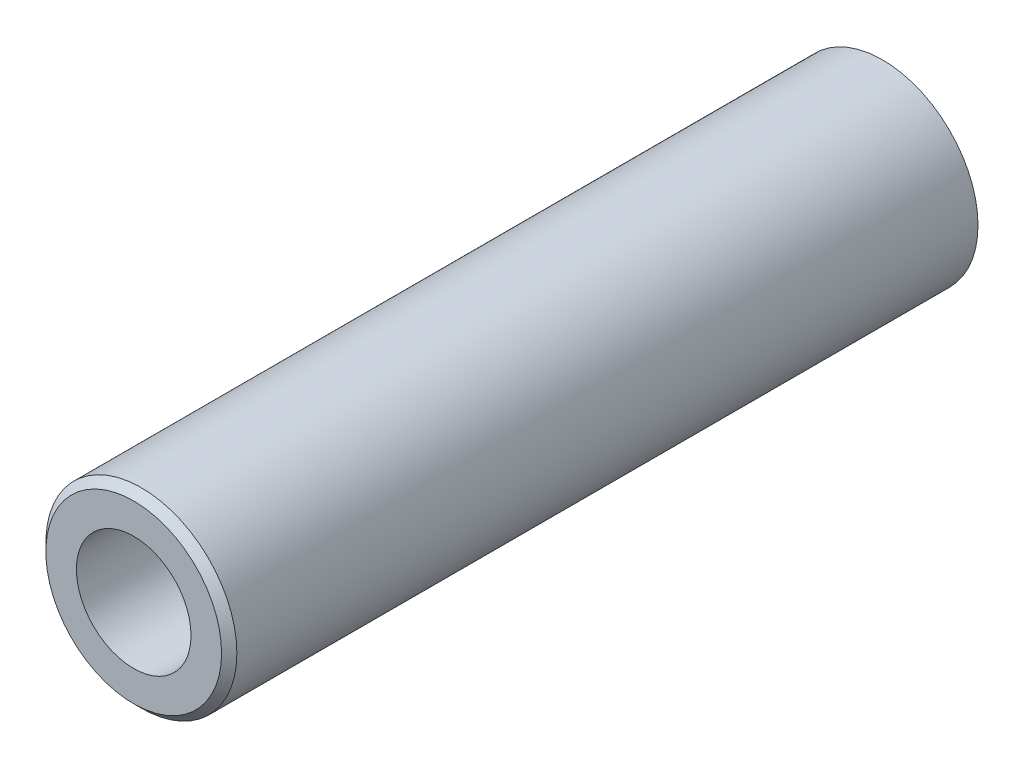
from build123d import *

# Parameters (mm, degrees)
SKETCH1_R           = 6.25
SKETCH1_R_2         = 3.75
EXTRUDE_THIN1_DEPTH = 24.5
CHAMFER1_SIZE       = 0.5


with BuildPart() as part:
    # Sketch1 → Extrude-Thin1 (new body, symmetric)
    with BuildSketch(Plane.XY):
        Circle(SKETCH1_R)
        Circle(SKETCH1_R_2, mode=Mode.SUBTRACT)
    extrude(amount=EXTRUDE_THIN1_DEPTH, both=True)

    # Chamfer1
    chamfer1_edges = [part.edges().sort_by_distance(p)[0] for p in [
        (-6.25, 0, 24.5),
    ]]
    chamfer(chamfer1_edges, length=CHAMFER1_SIZE)


solid = part.part
